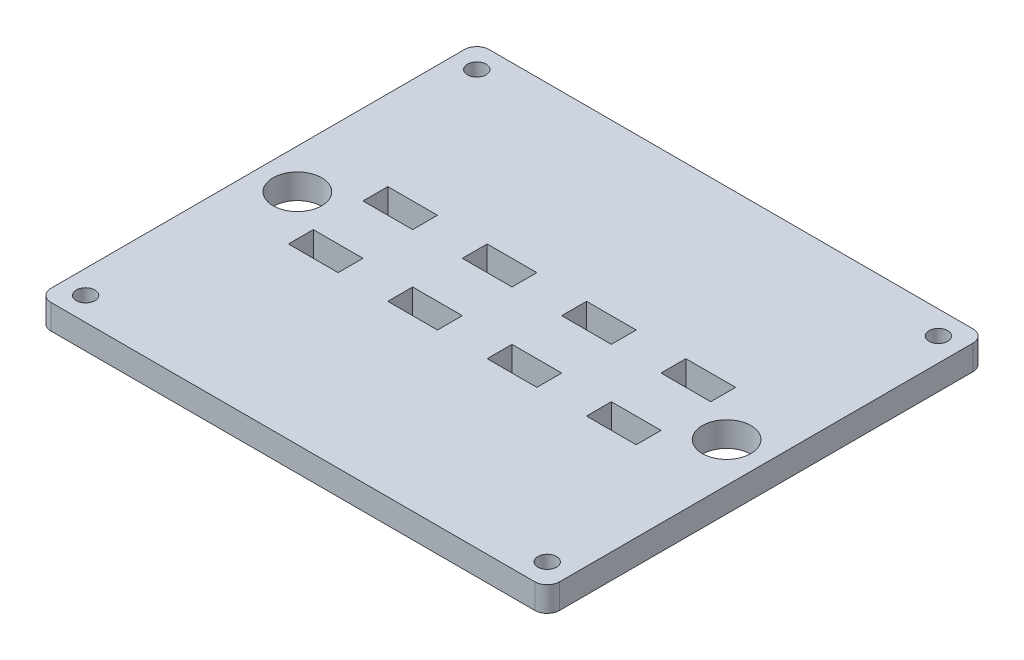
from build123d import *

# Parameters (mm, degrees)
SKETCH1_W           = 65
SKETCH1_H           = 56
BOSS_EXTRUDE1_DEPTH = 3.175
SKETCH2_R           = 1.190625
SKETCH2_W           = 6.35
SKETCH2_H           = 3.175
CUT_EXTRUDE1_DEPTH  = 3.175
FILLET1_R           = 1.5875
SKETCH3_R           = 3.106099532
CUT_EXTRUDE2_DEPTH  = 3.175


with BuildPart() as part:
    # Sketch1 → Boss-Extrude1 (new body)
    with BuildSketch(Plane(origin=(0, 0, 0), x_dir=(1, 0, 0), z_dir=(0, 1, 0))):
        with Locations((32.5, 28)):
            Rectangle(SKETCH1_W, SKETCH1_H)
    extrude(amount=BOSS_EXTRUDE1_DEPTH)

    # Sketch2 → Cut-Extrude1 (cut)
    with BuildSketch(Plane(origin=(0, 3.175, 0), x_dir=(1, 0, 0), z_dir=(0, 1, 0))):
        with Locations((62, 53)):
            Circle(SKETCH2_R)
        with Locations((3, 53)):
            Circle(SKETCH2_R)
        with Locations((3, 3)):
            Circle(SKETCH2_R)
        with Locations((62, 3)):
            Circle(SKETCH2_R)
        with Locations((13.45, 32.7625)):
            Rectangle(SKETCH2_W, SKETCH2_H)
        with Locations((38.85, 32.7625)):
            Rectangle(SKETCH2_W, SKETCH2_H)
        with Locations((51.55, 32.7625)):
            Rectangle(SKETCH2_W, SKETCH2_H)
        with Locations((26.15, 32.7625)):
            Rectangle(SKETCH2_W, SKETCH2_H)
        with Locations((26.15, 23.2375)):
            Rectangle(SKETCH2_W, SKETCH2_H)
        with Locations((13.45, 23.2375)):
            Rectangle(SKETCH2_W, SKETCH2_H)
        with Locations((51.55, 23.2375)):
            Rectangle(SKETCH2_W, SKETCH2_H)
        with Locations((38.85, 23.2375)):
            Rectangle(SKETCH2_W, SKETCH2_H)
    extrude(amount=-CUT_EXTRUDE1_DEPTH, mode=Mode.SUBTRACT)

    # Fillet1
    fillet1_edges = [part.edges().sort_by_distance(p)[0] for p in [
        (0, 1.5875, -56),
        (65, 1.5875, -56),
        (65, 1.5875, 0),
        (0, 1.5875, 0),
    ]]
    fillet(fillet1_edges, radius=FILLET1_R)

    # Sketch3 → Cut-Extrude2 (cut)
    with BuildSketch(Plane(origin=(0, 3.175, 0), x_dir=(1, 0, 0), z_dir=(0, 1, 0))):
        with Locations((5.068, 28)):
            Circle(SKETCH3_R)
        with Locations((59.932, 28)):
            Circle(SKETCH3_R)
    extrude(amount=-CUT_EXTRUDE2_DEPTH, mode=Mode.SUBTRACT)


solid = part.part
